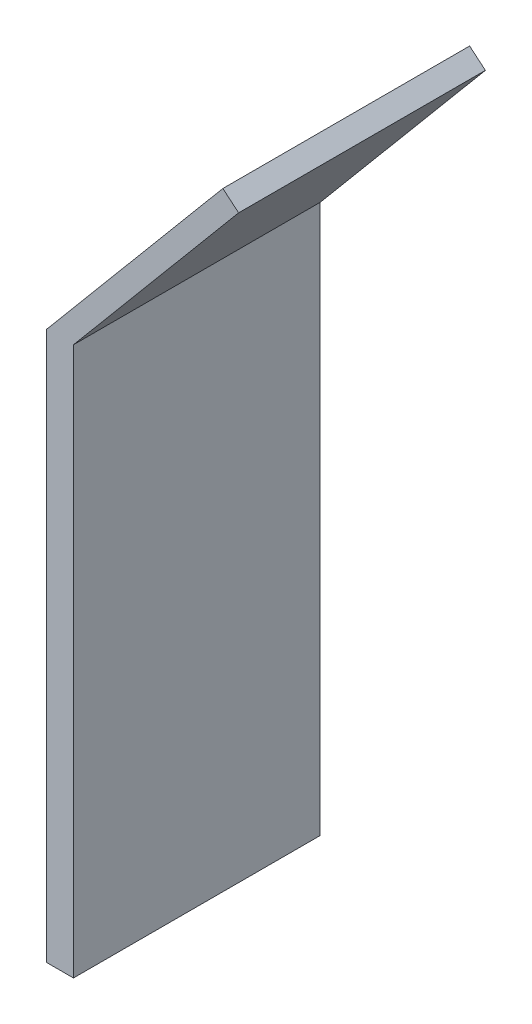
from build123d import *

# Parameters (mm, degrees)
BOSS_EXTRU_1_DEPTH      = 18
BOSS_EXTRU_1_DEPTH_BACK = 18


with BuildPart() as part:
    # Esquisse1 → Boss.-Extru.1 (new, two sides: drawn at the far end of the back side and taken through both)
    with BuildSketch(Plane.XY.offset(-BOSS_EXTRU_1_DEPTH_BACK)):
        Polygon((0, 0), (0, 80), (25.711504387, 110.641777725), (28.009637717, 108.713414896), (3.916221868, 80), (3.916221868, 0), align=None)
    extrude(amount=BOSS_EXTRU_1_DEPTH + BOSS_EXTRU_1_DEPTH_BACK)


solid = part.part
